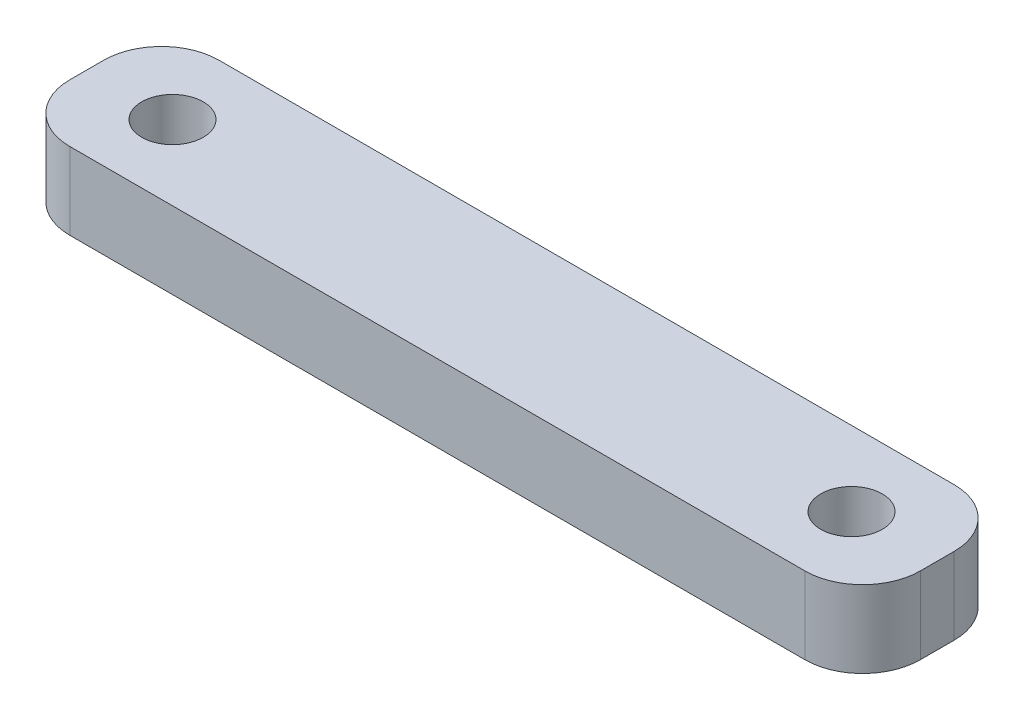
from build123d import *

# Parameters (mm, degrees)
SKETCH_1_W      = 44.217702276
SKETCH_1_H      = 7.762687128
SKETCH_1_R      = 1.6
EXTRUDE_1_DEPTH = 4
FILLET_1_R      = 3


with BuildPart() as part:
    # 草图1 → 凸台-拉伸1 (new body)
    with BuildSketch(Plane(origin=(0, 0, 0), x_dir=(1, 0, 0), z_dir=(0, 1, 0))):
        Rectangle(SKETCH_1_W, SKETCH_1_H)
        with Locations((-17.65, 0)):
            Circle(SKETCH_1_R, mode=Mode.SUBTRACT)
        with Locations((17.65, 0)):
            Circle(SKETCH_1_R, mode=Mode.SUBTRACT)
    extrude(amount=EXTRUDE_1_DEPTH)

    # 圆角1
    fillet_1_edges = [part.edges().sort_by_distance(p)[0] for p in [
        (-22.108851138, 2, -3.881343564),
        (22.108851138, 2, -3.881343564),
        (22.108851138, 2, 3.881343564),
        (-22.108851138, 2, 3.881343564),
    ]]
    fillet(fillet_1_edges, radius=FILLET_1_R)


solid = part.part
